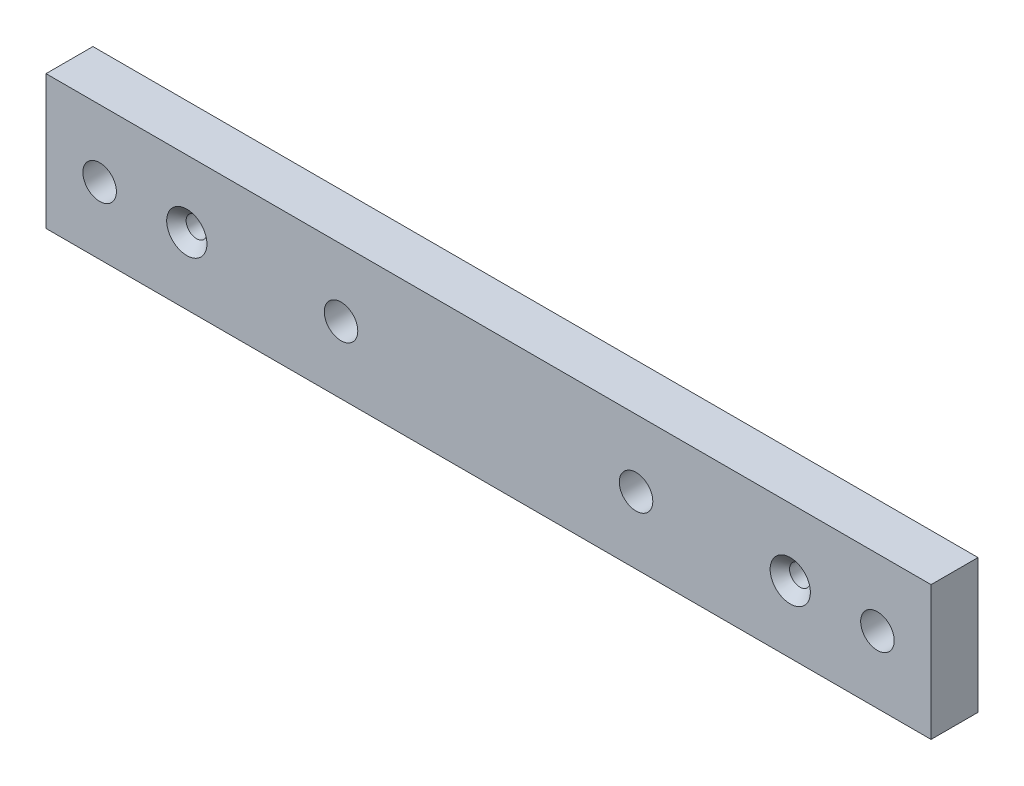
from build123d import *

# Parameters (mm, degrees)
SKETCH1_W                                           = 132
SKETCH1_H                                           = 20
SKETCH1_R                                           = 1.5
SKETCH1_R_2                                         = 2.5
BOSS_EXTRUDE1_DEPTH                                 = 7
CSK_FOR_M4_COUNTERSUNK_FLAT_HEAD_SCREW1_D           = 3.1
CSK_FOR_M4_COUNTERSUNK_FLAT_HEAD_SCREW1_CSINK_D     = 6
CSK_FOR_M4_COUNTERSUNK_FLAT_HEAD_SCREW1_CSINK_ANGLE = 90


with BuildPart() as part:
    # Sketch1 → Boss-Extrude1 (new body)
    with BuildSketch(Plane.XY):
        Rectangle(SKETCH1_W, SKETCH1_H)
        with Locations((-45, 0)):
            Circle(SKETCH1_R, mode=Mode.SUBTRACT)
        with Locations((45, 0)):
            Circle(SKETCH1_R, mode=Mode.SUBTRACT)
        with Locations((-22, 0)):
            Circle(SKETCH1_R_2, mode=Mode.SUBTRACT)
        with Locations((22, 0)):
            Circle(SKETCH1_R_2, mode=Mode.SUBTRACT)
        with Locations((-58, 0)):
            Circle(SKETCH1_R_2, mode=Mode.SUBTRACT)
        with Locations((58, 0)):
            Circle(SKETCH1_R_2, mode=Mode.SUBTRACT)
    extrude(amount=BOSS_EXTRUDE1_DEPTH)

    # CSK for M4 Countersunk Flat Head Screw1 (through all)
    with Locations(Plane(origin=(-45, 0, 7), x_dir=(1, 0, 0), z_dir=(0, 0, 1))):
        with Locations((0, 0), (90, 0)):
            CounterSinkHole(CSK_FOR_M4_COUNTERSUNK_FLAT_HEAD_SCREW1_D / 2, CSK_FOR_M4_COUNTERSUNK_FLAT_HEAD_SCREW1_CSINK_D / 2, counter_sink_angle=CSK_FOR_M4_COUNTERSUNK_FLAT_HEAD_SCREW1_CSINK_ANGLE)


solid = part.part
